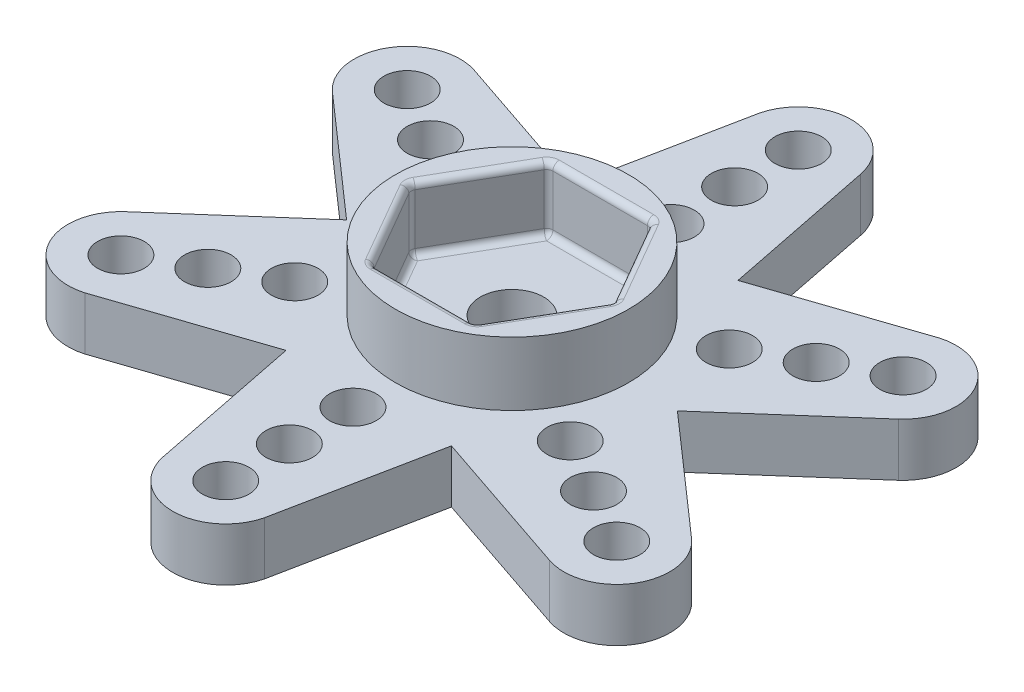
from build123d import *

# Parameters (mm, degrees)
SALIENTE_EXTRUIR1_DEPTH = 2.5
CROQUIS2_R              = 5.5
SALIENTE_EXTRUIR2_DEPTH = 3
CORTAR_EXTRUIR1_REACH   = 7.5
CROQUIS3_R              = 1.5
CROQUIS4_R              = 4.3
CORTAR_EXTRUIR2_DEPTH   = 1
CROQUIS5_R              = 4.5
CROQUIS5_R_2            = 4.3
CORTAR_EXTRUIR3_DEPTH   = 0.5
REDONDEO1_R             = 0.3
CROQUIS6_R              = 1.1
CORTAR_EXTRUIR4_DEPTH   = 2.5
MATRIZC1_COUNT          = 6


with BuildPart() as part:
    # Croquis1 → Saliente-Extruir1 (new body)
    with BuildSketch(Plane(origin=(0, 0, 0), x_dir=(1, 0, 0), z_dir=(0, 1, 0))):
        with BuildLine():
            Line((-3.9, -6.75499815), (-10.994862545, -9.151023749))
            ThreePointArc((-10.994862545, -9.151023749), (-13.88318634, -7.952423618), (-13.342044439, -4.872452504))
            Line((-13.342044439, -4.872452504), (-7.8, 0))
            Line((-7.8, 0), (-13.42245031, 4.9463184))
            ThreePointArc((-13.42245031, 4.9463184), (-13.828594045, 8.046980247), (-10.890689867, 9.11832317))
            Line((-10.890689867, 9.11832317), (-3.9, 6.75499815))
            Line((-3.9, 6.75499815), (-2.427587765, 14.097342149))
            ThreePointArc((-2.427587765, 14.097342149), (0.054592295, 15.999403865), (2.451354572, 13.990775674))
            Line((2.451354572, 13.990775674), (3.9, 6.75499815))
            Line((3.9, 6.75499815), (10.994862545, 9.151023749))
            ThreePointArc((10.994862545, 9.151023749), (13.88318634, 7.952423618), (13.342044439, 4.872452504))
            Line((13.342044439, 4.872452504), (7.8, 0))
            Line((7.8, 0), (13.42245031, -4.9463184))
            ThreePointArc((13.42245031, -4.9463184), (13.828594045, -8.046980247), (10.890689867, -9.11832317))
            Line((10.890689867, -9.11832317), (3.9, -6.75499815))
            Line((3.9, -6.75499815), (2.427587765, -14.097342149))
            ThreePointArc((2.427587765, -14.097342149), (-0.054592295, -15.999403865), (-2.451354572, -13.990775674))
            Line((-2.451354572, -13.990775674), (-3.9, -6.75499815))
        make_face()
    extrude(amount=SALIENTE_EXTRUIR1_DEPTH)

    # Croquis2 → Saliente-Extruir2 (add)
    with BuildSketch(Plane(origin=(0, 2.5, 0), x_dir=(1, 0, 0), z_dir=(0, 1, 0))):
        Circle(CROQUIS2_R)
        Polygon((2.4, -4.156921938), (4.8, 0), (2.4, 4.156921938), (-2.4, 4.156921938), (-4.8, 0), (-2.4, -4.156921938), align=None, mode=Mode.SUBTRACT)
    extrude(amount=SALIENTE_EXTRUIR2_DEPTH)

    # Croquis3 → Cortar-Extruir1 (cut, up to next)
    with BuildSketch(Plane.XZ, mode=Mode.PRIVATE) as cortar_extruir1_sk1:
        Circle(CROQUIS3_R)
    cortar_extruir1_tool1 = extrude(cortar_extruir1_sk1.sketch, amount=-CORTAR_EXTRUIR1_REACH, mode=Mode.PRIVATE) & part.part
    add(cortar_extruir1_tool1.solids().sort_by_distance((0, 0, 0))[0], mode=Mode.SUBTRACT)

    # Croquis4 → Cortar-Extruir2 (cut)
    with BuildSketch(Plane.XZ):
        Circle(CROQUIS4_R)
    extrude(amount=-CORTAR_EXTRUIR2_DEPTH, mode=Mode.SUBTRACT)

    # Croquis5 → Cortar-Extruir3 (cut)
    with BuildSketch(Plane.XZ):
        Circle(CROQUIS5_R)
        Circle(CROQUIS5_R_2, mode=Mode.SUBTRACT)
    extrude(amount=-CORTAR_EXTRUIR3_DEPTH, mode=Mode.SUBTRACT)

    # Redondeo1
    redondeo1_edges = [part.edges().sort_by_distance(p)[0] for p in [
        (0, 2.5, 4.156921938),
        (3.6, 2.5, 2.078460969),
        (3.6, 2.5, -2.078460969),
        (0, 2.5, -4.156921938),
        (-3.6, 2.5, -2.078460969),
        (-3.6, 2.5, 2.078460969),
        (0, 5.5, 4.156921938),
        (2.4, 4, 4.156921938),
        (3.6, 5.5, 2.078460969),
        (4.8, 4, 0),
        (3.6, 5.5, -2.078460969),
        (2.4, 4, -4.156921938),
        (0, 5.5, -4.156921938),
        (-2.4, 4, -4.156921938),
        (-3.6, 5.5, -2.078460969),
        (-4.8, 4, 0),
        (-3.6, 5.5, 2.078460969),
        (-2.4, 4, 4.156921938),
    ]]
    fillet(redondeo1_edges, radius=REDONDEO1_R)

    # Croquis6 → Cortar-Extruir4 (cut)
    with BuildSketch(Plane.XZ):
        with Locations((0, -13.5)):
            Circle(CROQUIS6_R)
        with Locations((0, -10.5)):
            Circle(CROQUIS6_R)
        with Locations((0, -7.5)):
            Circle(CROQUIS6_R)
    cortar_extruir4 = extrude(amount=-CORTAR_EXTRUIR4_DEPTH, mode=Mode.SUBTRACT)

    # MatrizC1: Cortar-Extruir4 ×6 about axis
    matrizc1_axis = Axis((0, 0, 0), (0, 1, 0))
    for i in range(1, MATRIZC1_COUNT):
        add(cortar_extruir4.rotate(matrizc1_axis, i * 360 / MATRIZC1_COUNT), mode=Mode.SUBTRACT)


solid = part.part
